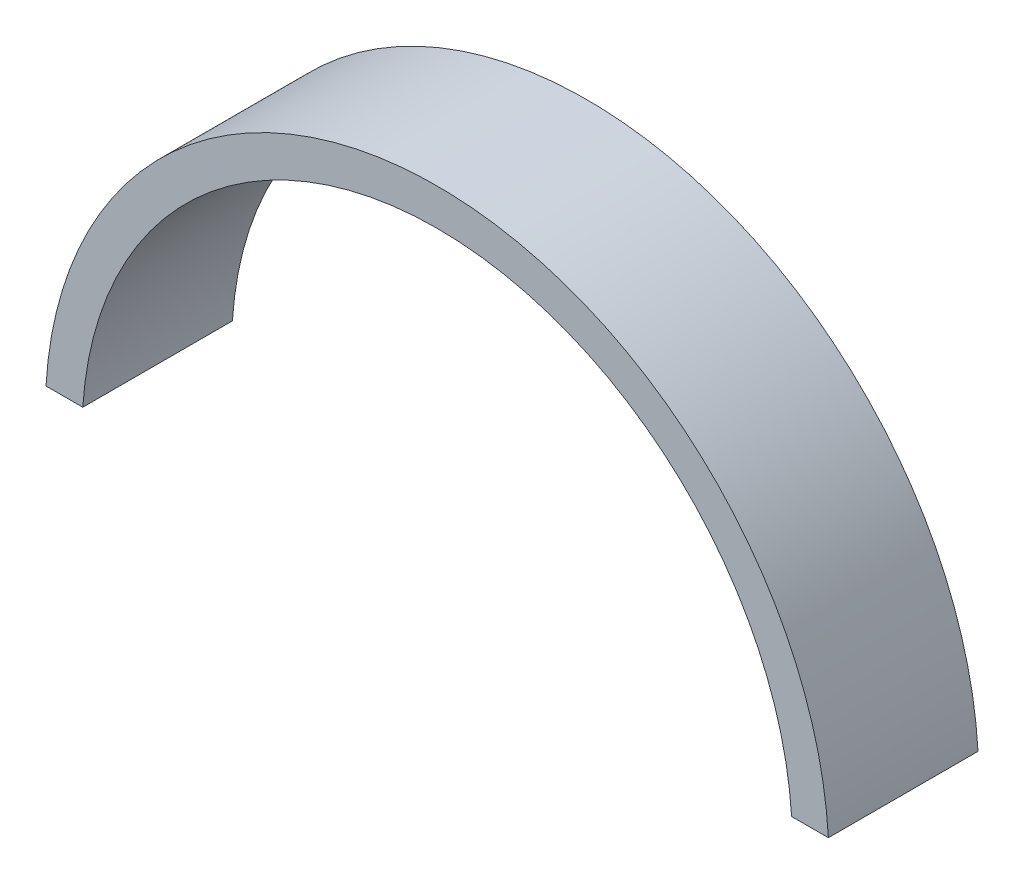
from build123d import *

# Parameters (mm, degrees)
BOSS_EXTRUDE1_DEPTH = 30


with BuildPart() as part:
    # Sketch1 → Boss-Extrude1 (new body)
    with BuildSketch(Plane.XY):
        with BuildLine():
            ThreePointArc((78.43801195, 4.610764133), (0, 78.573410671), (-78.43801195, 4.610764133))
            Line((-78.43801195, 4.610764133), (-71.062529975, 4.610764133))
            ThreePointArc((-71.062529975, 4.610764133), (0, 71.211953437), (71.062529975, 4.610764133))
            Line((71.062529975, 4.610764133), (78.43801195, 4.610764133))
        make_face()
    extrude(amount=BOSS_EXTRUDE1_DEPTH)


solid = part.part
